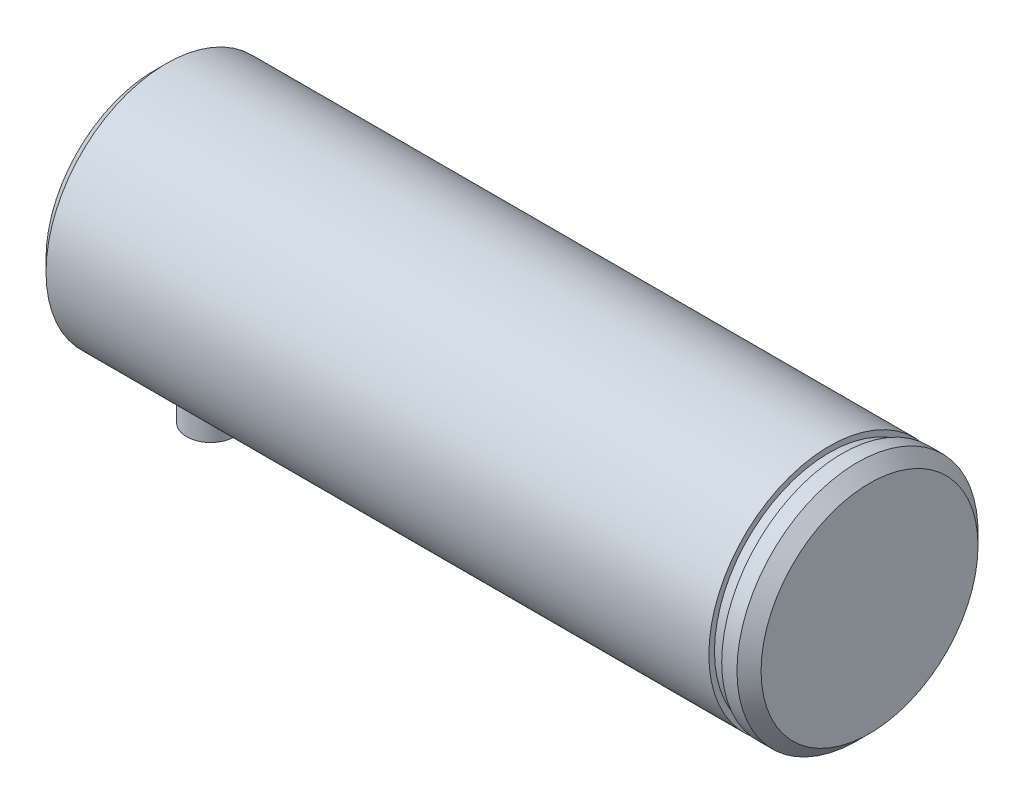
from build123d import *

# Parameters (mm, degrees)
SKETCH1_W           = 84
SKETCH1_H           = 15
SKETCH3_R           = 3
BOSS_EXTRUDE1_DEPTH = 21
SKETCH4_W           = 5
SKETCH4_H           = 15
SKETCH5_W           = 1.6
SKETCH5_H           = 0.7


with BuildPart() as part:
    # Sketch1 → Revolve1 (revolve)
    with BuildSketch(Plane.XY):
        with Locations((-2.5, 7.5)):
            Rectangle(SKETCH1_W, SKETCH1_H)
    revolve(axis=Axis((39.5, 0, 0), (-1, 0, 0)))

    # Sketch2 → Cut-Revolve1 (revolve, cut)
    with BuildSketch(Plane.XY):
        Polygon((-44.5, 13.5), (-43, 15), (-44.5, 15), align=None)
    revolve(axis=Axis((77, 0, 0), (-1, 0, 0)), mode=Mode.SUBTRACT)

    # Sketch3 → Boss-Extrude1 (add)
    with BuildSketch(Plane(origin=(0, 0, 0), x_dir=(1, 0, 0), z_dir=(0, 1, 0))):
        with Locations((-37.5, 0)):
            Circle(SKETCH3_R)
    extrude(amount=-BOSS_EXTRUDE1_DEPTH)

    # Sketch4 → Revolve2 (revolve)
    with BuildSketch(Plane.XY):
        with Locations((42, 7.5)):
            Rectangle(SKETCH4_W, SKETCH4_H)
    revolve(axis=Axis((44.5, 0, 0), (-1, 0, 0)))

    # Sketch5 → Cut-Revolve2 (revolve, cut)
    with BuildSketch(Plane.XY):
        with Locations((40.3, 14.65)):
            Rectangle(SKETCH5_W, SKETCH5_H)
    revolve(axis=Axis((77, 0, 0), (-1, 0, 0)), mode=Mode.SUBTRACT)

    # Sketch6 → Cut-Revolve3 (revolve, cut)
    with BuildSketch(Plane.XY):
        Polygon((43, 15), (44.5, 13.5), (44.5, 15), align=None)
    revolve(axis=Axis((77, 0, 0), (-1, 0, 0)), mode=Mode.SUBTRACT)


solid = part.part
